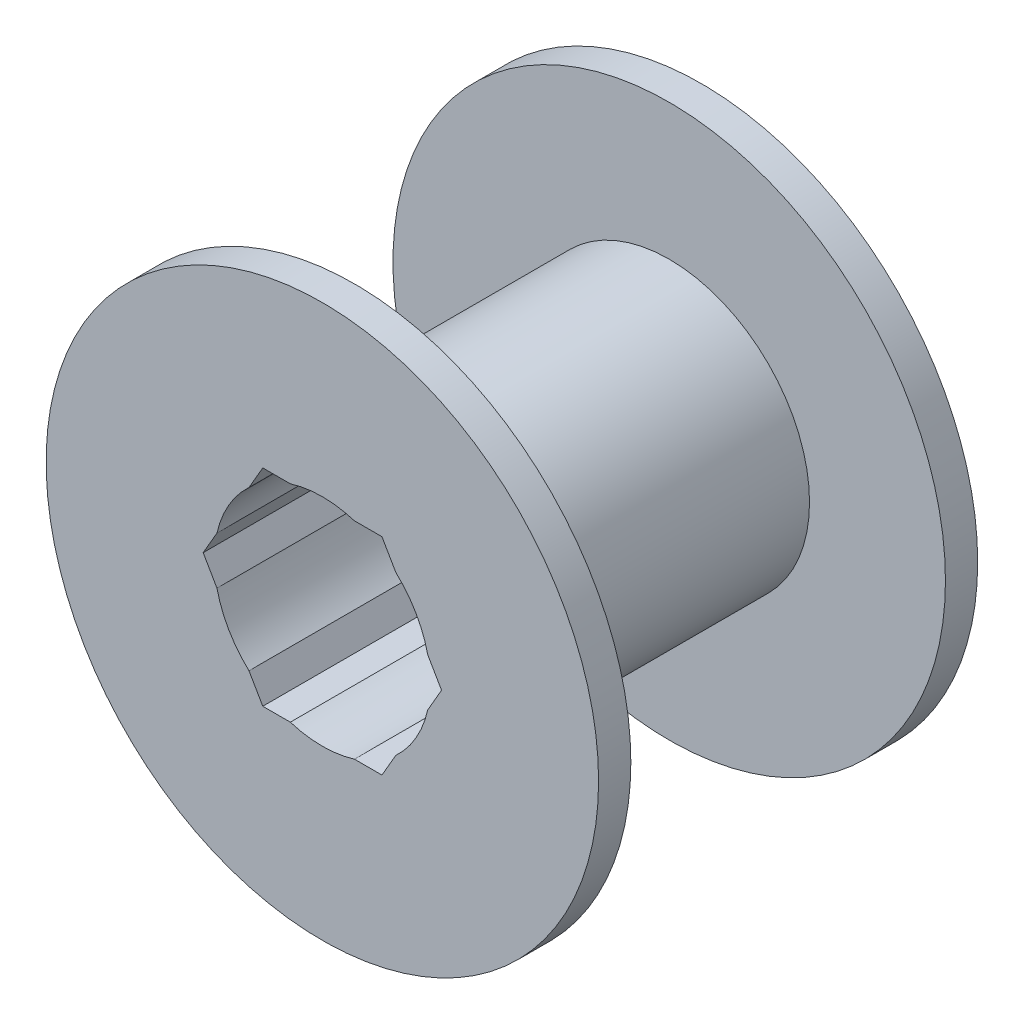
from build123d import *

# Parameters (mm, degrees)
CUT_EXTRUDE1_DEPTH = 48.098407616


with BuildPart() as part:
    # Sketch1 → Revolve1 (revolve)
    with BuildSketch(Plane(origin=(0, 0, 0), x_dir=(0, 0, -1), z_dir=(1, 0, 0))):
        Polygon((-13.61, 23.9), (-13.61, 12.14), (13.61, 12.14), (13.61, 23.9), (16.4, 23.9), (16.4, 9.35), (-16.4, 9.35), (-16.4, 23.9), align=None)
    revolve(axis=Axis((0, 0, 33.448920863), (0, 0, -1)))

    # Sketch2 → Cut-Extrude1 (cut, through all)
    with BuildSketch(Plane.XY.offset(16.4)):
        Polygon((5.155737904, 8.93), (-5.155737904, 8.93), (-10.311475808, 0), (-5.155737904, -8.93), (5.155737904, -8.93), (10.311475808, 0), align=None)
    extrude(amount=-CUT_EXTRUDE1_DEPTH, mode=Mode.SUBTRACT)


solid = part.part
